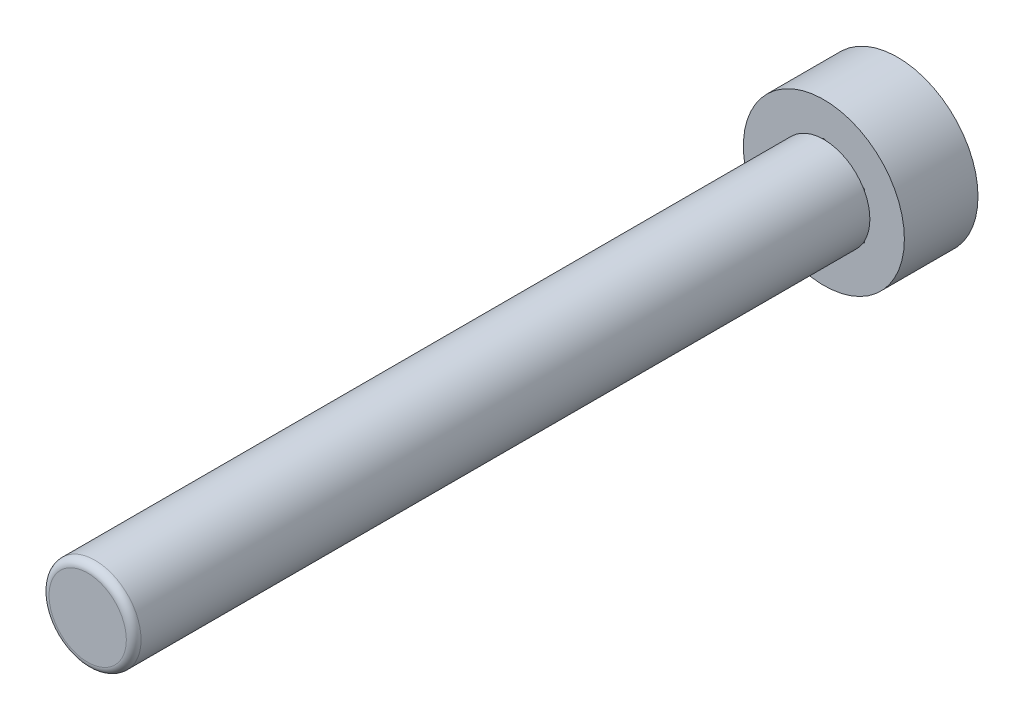
from build123d import *

# Parameters (mm, degrees)
SKETCH1_R           = 5.55625
BOSS_EXTRUDE1_DEPTH = 5.08
SKETCH2_R           = 3.175
BOSS_EXTRUDE2_DEPTH = 50.8
FILLET1_R           = 0.508


with BuildPart() as part:
    # Sketch1 → Boss-Extrude1 (new body)
    with BuildSketch(Plane.XY):
        Circle(SKETCH1_R)
        Polygon((2.794, 1.613116652), (0, 3.226233304), (-2.794, 1.613116652), (-2.794, -1.613116652), (0, -3.226233304), (2.794, -1.613116652), align=None, mode=Mode.SUBTRACT)
    extrude(amount=BOSS_EXTRUDE1_DEPTH)

    # Sketch2 → Boss-Extrude2 (add)
    with BuildSketch(Plane.XY.offset(5.08)):
        Circle(SKETCH2_R)
    extrude(amount=BOSS_EXTRUDE2_DEPTH)

    # Fillet1
    fillet1_edges = [part.edges().sort_by_distance(p)[0] for p in [
        (-3.175, 0, 55.88),
    ]]
    fillet(fillet1_edges, radius=FILLET1_R)


solid = part.part
